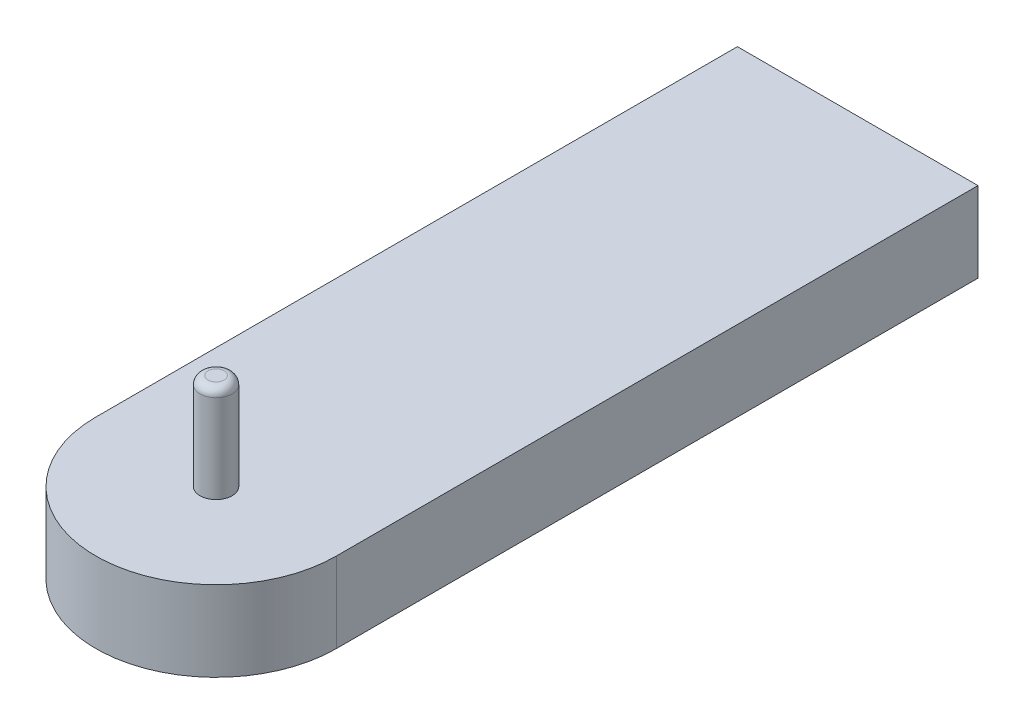
from build123d import *

# Parameters (mm, degrees)
EXTRUDE_1_DEPTH = 50
SKETCH_2_R      = 10
EXTRUDE_2_DEPTH = 60
FILLET_1_R      = 5


with BuildPart() as part:
    # 草图1 → 凸台-拉伸1 (new body)
    with BuildSketch(Plane(origin=(0, 0, 0), x_dir=(1, 0, 0), z_dir=(0, 1, 0))):
        with BuildLine():
            Line((0, 0), (150, 0))
            Line((150, 0), (150, -400))
            ThreePointArc((150, -400), (75, -475), (0, -400))
            Line((0, -400), (0, 0))
        make_face()
    extrude(amount=EXTRUDE_1_DEPTH)

    # 草图2 → 凸台-拉伸2 (add)
    with BuildSketch(Plane(origin=(0, 50, 0), x_dir=(1, 0, 0), z_dir=(0, 1, 0))):
        with Locations((75, -400)):
            Circle(SKETCH_2_R)
    extrude(amount=EXTRUDE_2_DEPTH)

    # 圆角1
    fillet_1_edges = [part.edges().sort_by_distance(p)[0] for p in [
        (65, 110, 400),
    ]]
    fillet(fillet_1_edges, radius=FILLET_1_R)


solid = part.part
